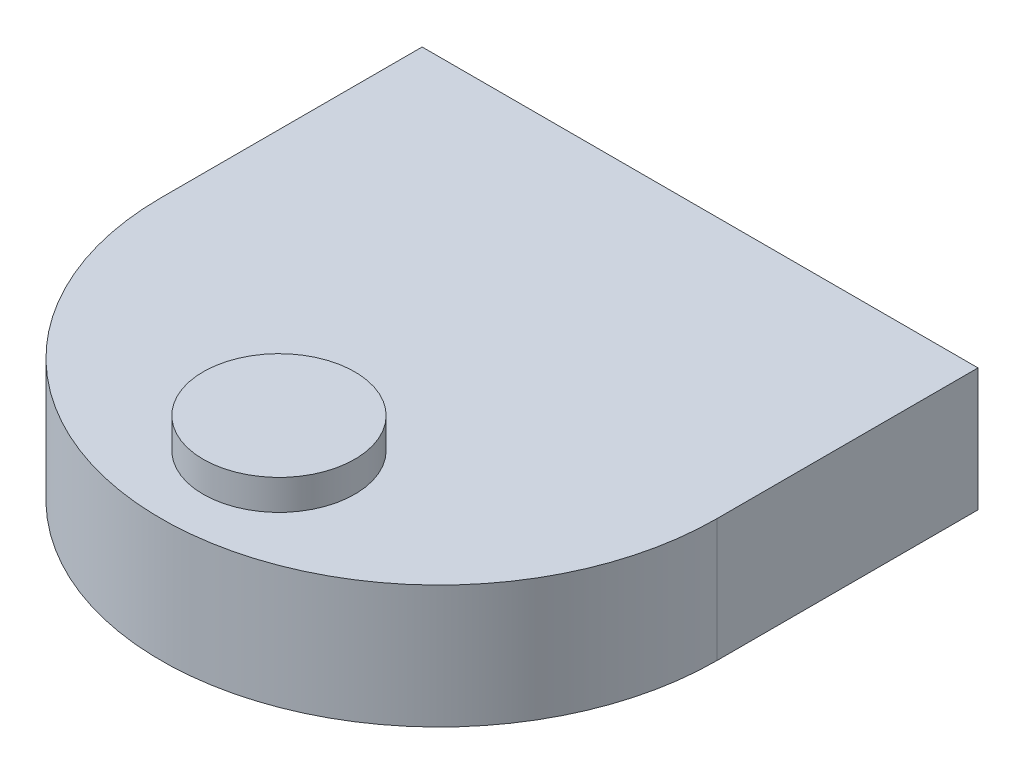
from build123d import *

# Parameters (mm, degrees)
BOSS_EXTRUDE1_DEPTH  = 73
SKETCH2_R            = 45
BOSS_EXTRUDE2_DEPTH  = 18
SKETCH3_W            = 20
SKETCH3_H            = 80
CUT_EXTRUDE2_DEPTH   = 27.5
SKETCH5_W            = 20
SKETCH5_H            = 40
LPATTERN2_COUNT      = 2
LPATTERN2_PITCH      = 180
LPATTERN2_COUNT_DIR2 = 2
LPATTERN2_PITCH_DIR2 = 200


with BuildPart() as part:
    # Sketch1 → Boss-Extrude1 (new body)
    with BuildSketch(Plane(origin=(0, 0, 0), x_dir=(1, 0, 0), z_dir=(0, 1, 0))):
        with BuildLine():
            ThreePointArc((-56.568542495, 155), (-135.201348942, 94.581156919), (-165, 0))
            ThreePointArc((-165, 0), (0, -165), (165, 0))
            ThreePointArc((165, 0), (135.201348942, 94.581156919), (56.568542495, 155))
            Line((56.568542495, 155), (-56.568542495, 155))
        make_face()
        with BuildLine():
            Line((-165, 155), (-165, 0))
            ThreePointArc((-165, 0), (-135.201348942, 94.581156919), (-56.568542495, 155))
            Line((-56.568542495, 155), (-165, 155))
        make_face()
        with BuildLine():
            ThreePointArc((56.568542495, 155), (135.201348942, 94.581156919), (165, 0))
            Line((165, 0), (165, 155))
            Line((165, 155), (56.568542495, 155))
        make_face()
    extrude(amount=BOSS_EXTRUDE1_DEPTH)

    # Sketch2 → Boss-Extrude2 (add)
    with BuildSketch(Plane(origin=(0, 73, 0), x_dir=(1, 0, 0), z_dir=(0, 1, 0))):
        with Locations((0, -95)):
            Circle(SKETCH2_R)
    extrude(amount=BOSS_EXTRUDE2_DEPTH)

    # Sketch4 one side → Revolve1 (revolve)
    with BuildSketch(Plane.XZ):
        with BuildLine():
            Line((-100, 100), (-80, 100))
            ThreePointArc((-80, 100), (-90, 110), (-100, 100))
        make_face()
    revolve1 = revolve(axis=Axis((-100, 0, 100), (1, 0, 0)))

    # Sketch3 → Cut-Extrude2 (cut)
    with BuildSketch(Plane.XZ):
        with Locations((-117.5, 0)):
            Rectangle(SKETCH3_W, SKETCH3_H)
        with Locations((117.5, 0)):
            Rectangle(SKETCH3_W, SKETCH3_H)
    extrude(amount=-CUT_EXTRUDE2_DEPTH, mode=Mode.SUBTRACT)

    # Sketch5 → Cut-Revolve2 (revolve, cut)
    with BuildSketch(Plane.XZ.offset(-27.5)):
        with Locations((-117.5, 20)):
            Rectangle(SKETCH5_W, SKETCH5_H)
        with Locations((117.5, 20)):
            Rectangle(SKETCH5_W, SKETCH5_H)
    revolve(axis=Axis((-127.5, 27.5, 0), (1, 0, 0)), mode=Mode.SUBTRACT)

    # LPattern2: Revolve1 2 × 2
    with Locations(*[(i * LPATTERN2_PITCH, 0, -j * LPATTERN2_PITCH_DIR2) for i in range(LPATTERN2_COUNT) for j in range(LPATTERN2_COUNT_DIR2) if (i, j) != (0, 0)]):
        add(revolve1)


solid = part.part
